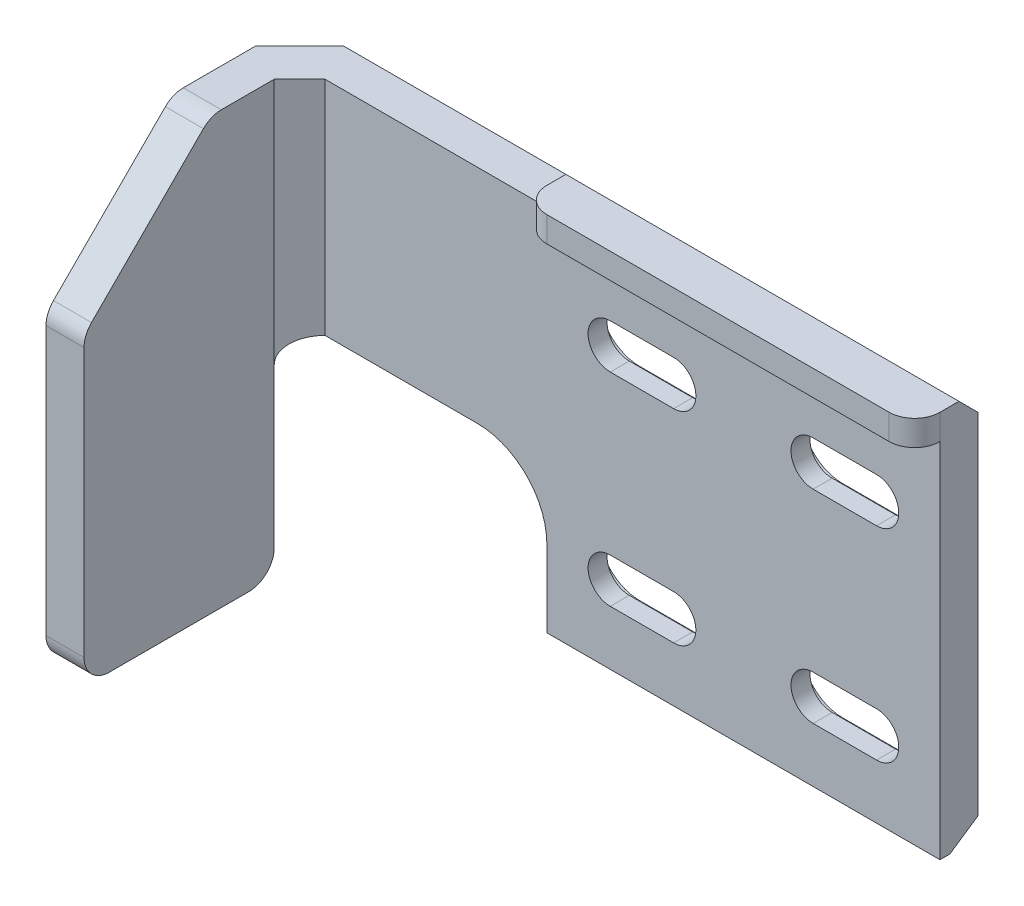
from build123d import *

# Parameters (mm, degrees)
BOSS_EXTRUDE1_DEPTH      = 3
SKETCH2_W                = 3
SKETCH2_H                = 34
BOSS_EXTRUDE2_DEPTH      = 17
BOSS_EXTRUDE2_DEPTH_BACK = 3
SKETCH3_W                = 22.5
SKETCH3_H                = 29.060921084
CUT_EXTRUDE1_DEPTH       = 18
CUT_EXTRUDE2_DEPTH       = 1.5
CHAMFER1_SIZE            = 10
CHAMFER2_SIZE            = 1.5
CHAMFER2_SIZE2           = 2.223841453
SKETCH7_W                = 31
SKETCH7_H                = 2
BOSS_EXTRUDE3_DEPTH      = 2
BOSS_EXTRUDE3_DEPTH_BACK = 3
SKETCH9_W                = 0.5
SKETCH9_H                = 11.560921084
CUT_EXTRUDE4_DEPTH       = 10
CHAMFER3_SIZE            = 1.5
CUT_EXTRUDE6_START       = -16.5
SKETCH11_W               = 3
SKETCH11_H               = 5
CUT_EXTRUDE6_DEPTH       = 16.5
CHAMFER9_SIZE            = 2
CHAMFER10_SIZE           = 3.5
FILLET2_R                = 2


with BuildPart() as part:
    # Sketch1 → Boss-Extrude1 (new body)
    with BuildSketch(Plane.XY):
        with BuildLine():
            Line((38, 38.915798387), (-38, 38.915798387))
            Line((-38, 38.915798387), (-38, 9.854877303))
            Line((-38, 9.854877303), (-34.5, 9.854877303))
            Line((-34.5, 9.854877303), (-34.5, 15.915798387))
            Line((-34.5, 15.915798387), (-34.5, 21.415798387))
            Line((-34.5, 21.415798387), (-29, 21.415798387))
            Line((-29, 21.415798387), (-21, 21.415798387))
            ThreePointArc((-21, 21.415798387), (-17.110912703, 19.804885683), (-15.5, 15.915798387))
            Line((-15.5, 15.915798387), (-15.5, 9.854877303))
            Line((-15.5, 9.854877303), (15.5, 9.854877303))
            Line((15.5, 9.854877303), (15.5, 15.915798387))
            ThreePointArc((15.5, 15.915798387), (17.110912703, 19.804885683), (21, 21.415798387))
            Line((21, 21.415798387), (29, 21.415798387))
            ThreePointArc((29, 21.415798387), (32.889087297, 19.804885683), (34.5, 15.915798387))
            Line((34.5, 15.915798387), (34.5, 9.854877303))
            Line((34.5, 9.854877303), (38, 9.854877303))
            Line((38, 9.854877303), (38, 38.915798387))
        make_face()
        with BuildLine():
            Line((-10.5, 33.665798387), (-5.5, 33.665798387))
            ThreePointArc((-5.5, 33.665798387), (-3.75, 31.915798387), (-5.5, 30.165798387))
            Line((-5.5, 30.165798387), (-10.5, 30.165798387))
            ThreePointArc((-10.5, 30.165798387), (-12.25, 31.915798387), (-10.5, 33.665798387))
        make_face(mode=Mode.SUBTRACT)
        with BuildLine():
            Line((5.5, 33.665798387), (10.5, 33.665798387))
            ThreePointArc((10.5, 33.665798387), (12.25, 31.915798387), (10.5, 30.165798387))
            Line((10.5, 30.165798387), (5.5, 30.165798387))
            ThreePointArc((5.5, 30.165798387), (3.75, 31.915798387), (5.5, 33.665798387))
        make_face(mode=Mode.SUBTRACT)
        with BuildLine():
            Line((5.5, 17.665798387), (10.5, 17.665798387))
            ThreePointArc((10.5, 17.665798387), (12.25, 15.915798387), (10.5, 14.165798387))
            Line((10.5, 14.165798387), (5.5, 14.165798387))
            ThreePointArc((5.5, 14.165798387), (3.75, 15.915798387), (5.5, 17.665798387))
        make_face(mode=Mode.SUBTRACT)
        with BuildLine():
            Line((-10.5, 17.665798387), (-5.5, 17.665798387))
            ThreePointArc((-5.5, 17.665798387), (-3.75, 15.915798387), (-5.5, 14.165798387))
            Line((-5.5, 14.165798387), (-10.5, 14.165798387))
            ThreePointArc((-10.5, 14.165798387), (-12.25, 15.915798387), (-10.5, 17.665798387))
        make_face(mode=Mode.SUBTRACT)
    extrude(amount=BOSS_EXTRUDE1_DEPTH)

    # Sketch2 → Boss-Extrude2 (add, two sides)
    with BuildSketch(Plane.XY.offset(3)) as boss_extrude2_sk:
        with Locations((-36.5, 21.915798387)):
            Rectangle(SKETCH2_W, SKETCH2_H)
    extrude(amount=BOSS_EXTRUDE2_DEPTH)
    extrude(boss_extrude2_sk.sketch, amount=-BOSS_EXTRUDE2_DEPTH_BACK)

    # Sketch3 → Cut-Extrude1 (cut)
    with BuildSketch(Plane.XY.offset(3)):
        with Locations((26.75, 24.385337845)):
            Rectangle(SKETCH3_W, SKETCH3_H)
    extrude(amount=-CUT_EXTRUDE1_DEPTH, mode=Mode.SUBTRACT)

    # Sketch4 → Cut-Extrude2 (cut)
    with BuildSketch(Plane(origin=(0, 0, 0), x_dir=(-1, 0, 0), z_dir=(0, 0, -1))):
        with BuildLine():
            Line((4.8, 35.115798387), (11.2, 35.115798387))
            ThreePointArc((11.2, 35.115798387), (14.4, 31.915798387), (11.2, 28.715798387))
            Line((11.2, 28.715798387), (4.8, 28.715798387))
            ThreePointArc((4.8, 28.715798387), (1.6, 31.915798387), (4.8, 35.115798387))
        make_face()
        with BuildLine():
            Line((-11.2, 35.115798387), (-4.8, 35.115798387))
            ThreePointArc((-4.8, 35.115798387), (-1.6, 31.915798387), (-4.8, 28.715798387))
            Line((-4.8, 28.715798387), (-11.2, 28.715798387))
            ThreePointArc((-11.2, 28.715798387), (-14.4, 31.915798387), (-11.2, 35.115798387))
        make_face()
        with BuildLine():
            Line((4.8, 19.115798387), (11.2, 19.115798387))
            ThreePointArc((11.2, 19.115798387), (14.4, 15.915798387), (11.2, 12.715798387))
            Line((11.2, 12.715798387), (4.8, 12.715798387))
            ThreePointArc((4.8, 12.715798387), (1.6, 15.915798387), (4.8, 19.115798387))
        make_face()
        with BuildLine():
            Line((-11.2, 19.115798387), (-4.8, 19.115798387))
            ThreePointArc((-4.8, 19.115798387), (-1.6, 15.915798387), (-4.8, 12.715798387))
            Line((-4.8, 12.715798387), (-11.2, 12.715798387))
            ThreePointArc((-11.2, 12.715798387), (-14.4, 15.915798387), (-11.2, 19.115798387))
        make_face()
    extrude(amount=-CUT_EXTRUDE2_DEPTH, mode=Mode.SUBTRACT)

    # Chamfer1
    chamfer1_edges = [part.edges().sort_by_distance(p)[0] for p in [
        (-36.5, 38.915798387, 20),
    ]]
    chamfer(chamfer1_edges, length=CHAMFER1_SIZE)

    # Chamfer2
    chamfer2_edges = [part.edges().sort_by_distance(p)[0] for p in [
        (0, 9.854877303, 0),
    ]]
    chamfer2_side = [part.faces().sort_by_distance(p)[0] for p in [
        (-11.889403283, 26.058636035, 0),
    ]]
    chamfer(chamfer2_edges, length=CHAMFER2_SIZE, length2=CHAMFER2_SIZE2, reference=chamfer2_side[0])

    # Sketch7 → Boss-Extrude3 (add, two sides)
    with BuildSketch(Plane.XY.offset(3)) as boss_extrude3_sk:
        with Locations((0, 39.415798387)):
            Rectangle(SKETCH7_W, SKETCH7_H)
    extrude(amount=BOSS_EXTRUDE3_DEPTH)
    extrude(boss_extrude3_sk.sketch, amount=-BOSS_EXTRUDE3_DEPTH_BACK)

    # Sketch9 → Cut-Extrude4 (cut)
    with BuildSketch(Plane(origin=(0, 0, 0), x_dir=(-1, 0, 0), z_dir=(0, 0, -1))):
        with Locations((34.75, 15.635337845)):
            Rectangle(SKETCH9_W, SKETCH9_H)
    extrude(amount=-CUT_EXTRUDE4_DEPTH, mode=Mode.SUBTRACT)

    # Chamfer3
    chamfer3_edges = [part.edges().sort_by_distance(p)[0] for p in [
        (0, 40.415798387, 0),
    ]]
    chamfer(chamfer3_edges, length=CHAMFER3_SIZE)

    # Sketch11 → Cut-Extrude6 (cut)
    with BuildSketch(Plane(origin=(0, 4.915798387, 0), x_dir=(-1, 0, 0), z_dir=(0, -1, 0)).offset(CUT_EXTRUDE6_START)):
        with Locations((36.5, -2.5)):
            Rectangle(SKETCH11_W, SKETCH11_H)
    extrude(amount=CUT_EXTRUDE6_DEPTH, mode=Mode.SUBTRACT)

    # Chamfer9
    chamfer9_edges = [part.edges().sort_by_distance(p)[0] for p in [
        (-35, 30.165798387, 3),
    ]]
    chamfer(chamfer9_edges, length=CHAMFER9_SIZE)

    # Chamfer10
    chamfer10_edges = [part.edges().sort_by_distance(p)[0] for p in [
        (-38, 30.165798387, 0),
    ]]
    chamfer(chamfer10_edges, length=CHAMFER10_SIZE)

    # Fillet2
    fillet2_edges = [part.edges().sort_by_distance(p)[0] for p in [
        (-36.5, 21.415798387, 5),
        (-36.5, 38.915798387, 10),
        (-36.5, 28.915798387, 20),
        (-36.5, 4.915798387, 20),
        (-36.5, 4.915798387, 5),
        (-15.5, 39.415798387, 5),
        (15.5, 39.415798387, 5),
    ]]
    fillet(fillet2_edges, radius=FILLET2_R)


solid = part.part
